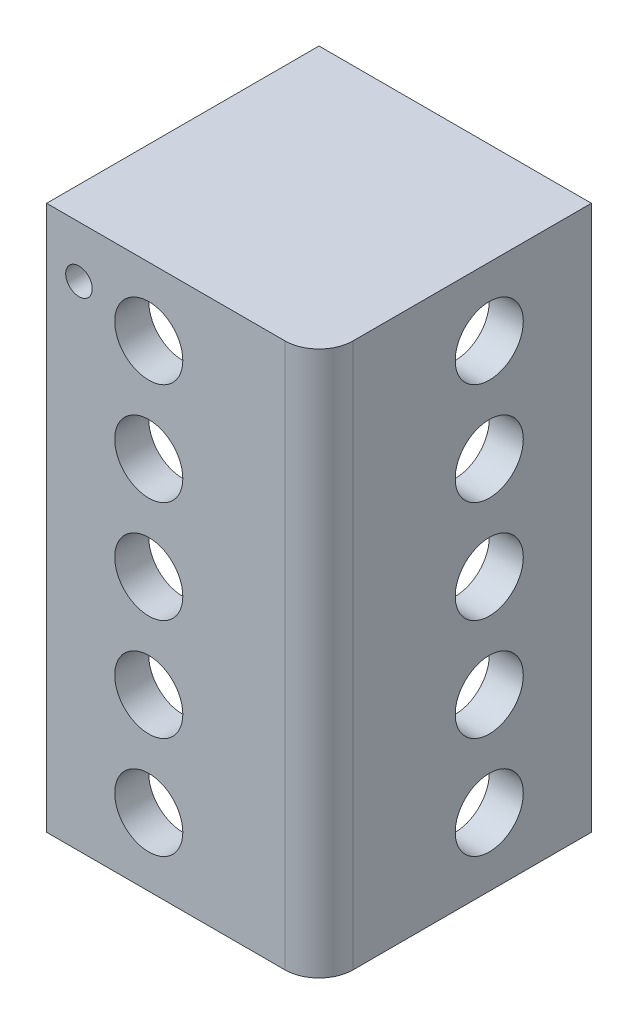
from build123d import *

# Parameters (mm, degrees)
SKETCH2_W               = 101.6
SKETCH2_H               = 101.6
BOSS_EXTRUDE1_DEPTH     = 203.2
SKETCH4_W               = 88.9
SKETCH4_H               = 88.9
CUT_EXTRUDE1_DEPTH      = 95.25
FILLET1_R               = 12.7
SKETCH5_R               = 12.7
CUT_EXTRUDE2_DEPTH      = 102.6
SKETCH6_R               = 12.7
CUT_EXTRUDE3_DEPTH      = 102.6
CUT_EXTRUDE4_DEPTH      = 7.35
SKETCH31_W              = 22.86
SKETCH31_H              = 8.89
BOSS_EXTRUDE2_DEPTH     = 25.4
FILLET5_R               = 12.7
FILLET6_R               = 6.35
SKETCH38_R              = 4.953
CUT_EXTRUDE7_DEPTH      = 50.022
CUT_EXTRUDE7_DEPTH_BACK = 53.578


with BuildPart() as part:
    # Sketch2 → Boss-Extrude1 (new body)
    with BuildSketch(Plane(origin=(0, 0, 0), x_dir=(1, 0, 0), z_dir=(0, 1, 0))):
        with Locations((9.448577681, 25.677899344)):
            Rectangle(SKETCH2_W, SKETCH2_H)
    extrude(amount=BOSS_EXTRUDE1_DEPTH)

    # Sketch4 → Cut-Extrude1 (cut, symmetric)
    with BuildSketch(Plane(origin=(0, 101.6, 0), x_dir=(1, 0, 0), z_dir=(0, 1, 0))):
        with Locations((3.098577681, 32.027899344)):
            Rectangle(SKETCH4_W, SKETCH4_H)
    extrude(amount=CUT_EXTRUDE1_DEPTH, both=True, mode=Mode.SUBTRACT)

    # Fillet1
    fillet1_edges = [part.edges().sort_by_distance(p)[0] for p in [
        (47.548577681, 101.6, 12.422100656),
        (60.248577681, 101.6, 25.122100656),
    ]]
    fillet(fillet1_edges, radius=FILLET1_R)

    # Sketch5 → Cut-Extrude2 (cut, through all)
    with BuildSketch(Plane.XY.offset(25.122100656)):
        with Locations((-3.251422319, 177.8)):
            Circle(SKETCH5_R)
        with Locations((-3.251422319, 139.7)):
            Circle(SKETCH5_R)
        with Locations((-3.251422319, 101.6)):
            Circle(SKETCH5_R)
        with Locations((-3.251422319, 63.5)):
            Circle(SKETCH5_R)
        with Locations((-3.251422319, 25.4)):
            Circle(SKETCH5_R)
    extrude(amount=-CUT_EXTRUDE2_DEPTH, mode=Mode.SUBTRACT)

    # Sketch6 → Cut-Extrude3 (cut, through all)
    with BuildSketch(Plane(origin=(60.248577681, 0, 0), x_dir=(0, 0, -1), z_dir=(1, 0, 0))):
        with Locations((38.377899344, 177.8)):
            Circle(SKETCH6_R)
        with Locations((38.377899344, 139.7)):
            Circle(SKETCH6_R)
        with Locations((38.377899344, 101.6)):
            Circle(SKETCH6_R)
        with Locations((38.377899344, 63.5)):
            Circle(SKETCH6_R)
        with Locations((38.377899344, 25.4)):
            Circle(SKETCH6_R)
    extrude(amount=-CUT_EXTRUDE3_DEPTH, mode=Mode.SUBTRACT)

    # Sketch7 → Cut-Extrude4 (cut, through all)
    with BuildSketch(Plane(origin=(0, 6.35, 0), x_dir=(1, 0, 0), z_dir=(0, 1, 0))):
        with BuildLine():
            Line((-41.351422319, 76.477899344), (47.548577681, 76.477899344))
            Line((47.548577681, 76.477899344), (47.548577681, 0.277899344))
            ThreePointArc((47.548577681, 0.277899344), (43.828833802, -8.702356778), (34.848577681, -12.422100656))
            Line((34.848577681, -12.422100656), (-41.351422319, -12.422100656))
            Line((-41.351422319, -12.422100656), (-41.351422319, 76.477899344))
        make_face()
    extrude(amount=-CUT_EXTRUDE4_DEPTH, mode=Mode.SUBTRACT)

    # Sketch31 → Boss-Extrude2 (add)
    with BuildSketch(Plane.XZ.offset(-196.85)):
        with Locations((-29.921422319, -2.182899344)):
            Rectangle(SKETCH31_W, SKETCH31_H)
        with Locations((-29.921422319, -23.010899344)):
            Rectangle(SKETCH31_W, SKETCH31_H)
    extrude(amount=BOSS_EXTRUDE2_DEPTH)

    # Fillet5
    fillet5_edges = [part.edges().sort_by_distance(p)[0] for p in [
        (-41.351422319, 171.45, -2.182899344),
        (-41.351422319, 171.45, -23.010899344),
    ]]
    fillet(fillet5_edges, radius=FILLET5_R)

    # Fillet6
    fillet6_edges = [part.edges().sort_by_distance(p)[0] for p in [
        (-18.491422319, 171.45, -2.182899344),
        (-18.491422319, 171.45, -23.010899344),
    ]]
    fillet(fillet6_edges, radius=FILLET6_R)

    # Sketch38 → Cut-Extrude7 (cut, two sides)
    with BuildSketch(Plane(origin=(0, 0, -27.455899344), x_dir=(-1, 0, 0), z_dir=(0, 0, -1))) as cut_extrude7_sk:
        with Locations((29.286422319, 184.023)):
            Circle(SKETCH38_R)
    extrude(amount=CUT_EXTRUDE7_DEPTH, mode=Mode.SUBTRACT)
    extrude(cut_extrude7_sk.sketch, amount=-CUT_EXTRUDE7_DEPTH_BACK, mode=Mode.SUBTRACT)


solid = part.part
